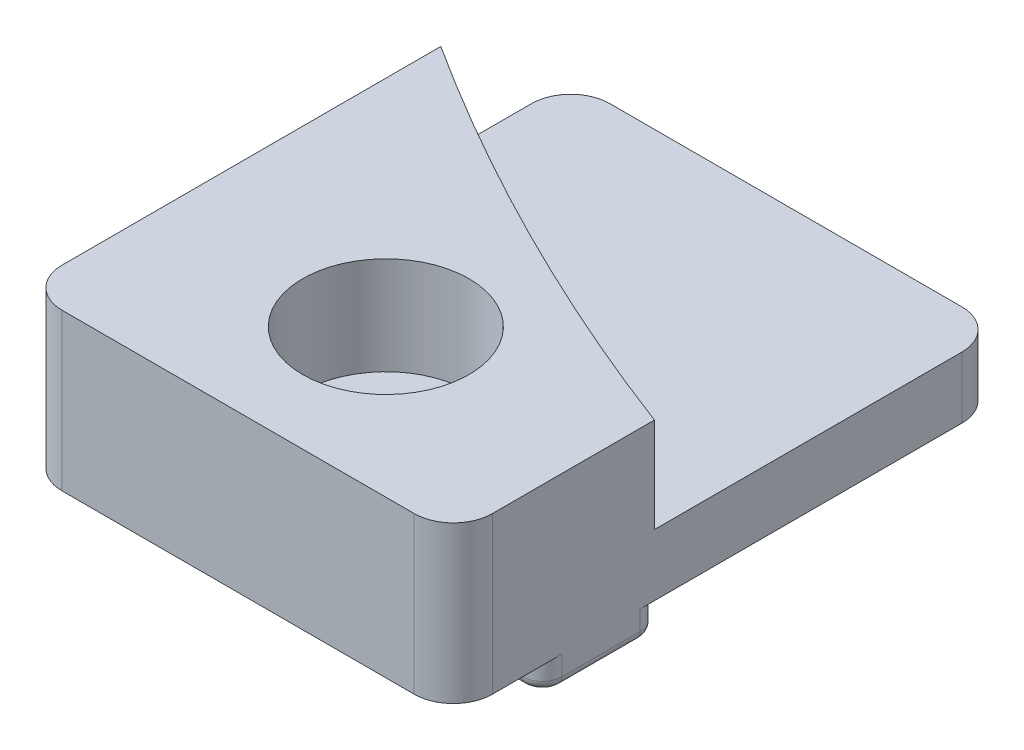
from build123d import *

# Parameters (mm, degrees)
SKETCH1_W                                        = 22
SKETCH1_H                                        = 28
BOSS_EXTRUDE1_DEPTH                              = 9.5
SKETCH2_W                                        = 17.45
SKETCH2_H                                        = 1.5
CUT_EXTRUDE1_DEPTH                               = 23
CUT_EXTRUDE2_DEPTH                               = 4.85
SKETCH4_W                                        = 4.55
SKETCH4_H                                        = 1.5
CUT_EXTRUDE3_DEPTH                               = 23
CBORE_FOR_M4_HEX_HEAD_MACHINE_SCREW1_D           = 4.3
CBORE_FOR_M4_HEX_HEAD_MACHINE_SCREW1_DEPTH       = 9.5
CBORE_FOR_M4_HEX_HEAD_MACHINE_SCREW1_CBORE_D     = 8.5
CBORE_FOR_M4_HEX_HEAD_MACHINE_SCREW1_CBORE_DEPTH = 5
FILLET1_R                                        = 1
FILLET2_R                                        = 0.5
FILLET3_R                                        = 2


with BuildPart() as part:
    # Sketch1 → Boss-Extrude1 (new body)
    with BuildSketch(Plane(origin=(0, 8, 0), x_dir=(1, 0, 0), z_dir=(0, 1, 0))):
        Rectangle(SKETCH1_W, SKETCH1_H)
    extrude(amount=-BOSS_EXTRUDE1_DEPTH)

    # Sketch2 → Cut-Extrude1 (cut, through all)
    with BuildSketch(Plane.ZY.offset(11)):
        with Locations((-5.275, -0.75)):
            Rectangle(SKETCH2_W, SKETCH2_H)
    extrude(amount=-CUT_EXTRUDE1_DEPTH, mode=Mode.SUBTRACT)

    # Sketch3 → Cut-Extrude2 (cut)
    with BuildSketch(Plane(origin=(0, 8, 0), x_dir=(-1, 0, 0), z_dir=(0, 1, 0))):
        with BuildLine():
            Line((11, -14), (11, -7.358592124))
            ThreePointArc((11, -7.358592124), (0.2873816, -1.249142024), (-11, 3.718814308))
            Line((-11, 3.718814308), (-11, -14))
            Line((-11, -14), (11, -14))
        make_face()
    extrude(amount=-CUT_EXTRUDE2_DEPTH, mode=Mode.SUBTRACT)

    # Sketch4 → Cut-Extrude3 (cut, through all)
    with BuildSketch(Plane.ZY.offset(11)):
        with Locations((11.725, -0.75)):
            Rectangle(SKETCH4_W, SKETCH4_H)
    extrude(amount=-CUT_EXTRUDE3_DEPTH, mode=Mode.SUBTRACT)

    # CBORE for M4 Hex Head Machine Screw1
    with Locations(Plane(origin=(0, 8, 0), x_dir=(1, 0, 0), z_dir=(0, 1, 0))):
        with Locations((0, -6.45)):
            CounterBoreHole(CBORE_FOR_M4_HEX_HEAD_MACHINE_SCREW1_D / 2, CBORE_FOR_M4_HEX_HEAD_MACHINE_SCREW1_CBORE_D / 2, CBORE_FOR_M4_HEX_HEAD_MACHINE_SCREW1_CBORE_DEPTH, depth=CBORE_FOR_M4_HEX_HEAD_MACHINE_SCREW1_DEPTH)

    # Fillet1
    fillet1_edges = [part.edges().sort_by_distance(p)[0] for p in [
        (11, -0.75, 3.45),
        (-11, -0.75, 3.45),
        (11, -0.75, 9.45),
        (-11, -0.75, 9.45),
    ]]
    fillet(fillet1_edges, radius=FILLET1_R)

    # Fillet2
    fillet2_edges = [part.edges().sort_by_distance(p)[0] for p in [
        (0, -1.5, 3.45),
        (-11, -1.5, 6.45),
        (11, -1.5, 6.45),
        (0, -1.5, 9.45),
        (10.707106781, -1.5, 9.157106781),
        (-10.707106781, -1.5, 9.157106781),
        (10.707106781, -1.5, 3.742893219),
        (-10.707106781, -1.5, 3.742893219),
    ]]
    fillet(fillet2_edges, radius=FILLET2_R)

    # Fillet3
    fillet3_edges = [part.edges().sort_by_distance(p)[0] for p in [
        (-11, 1.575, -14),
        (11, 1.575, -14),
        (-11, 4, 14),
        (11, 4, 14),
    ]]
    fillet(fillet3_edges, radius=FILLET3_R)


solid = part.part
